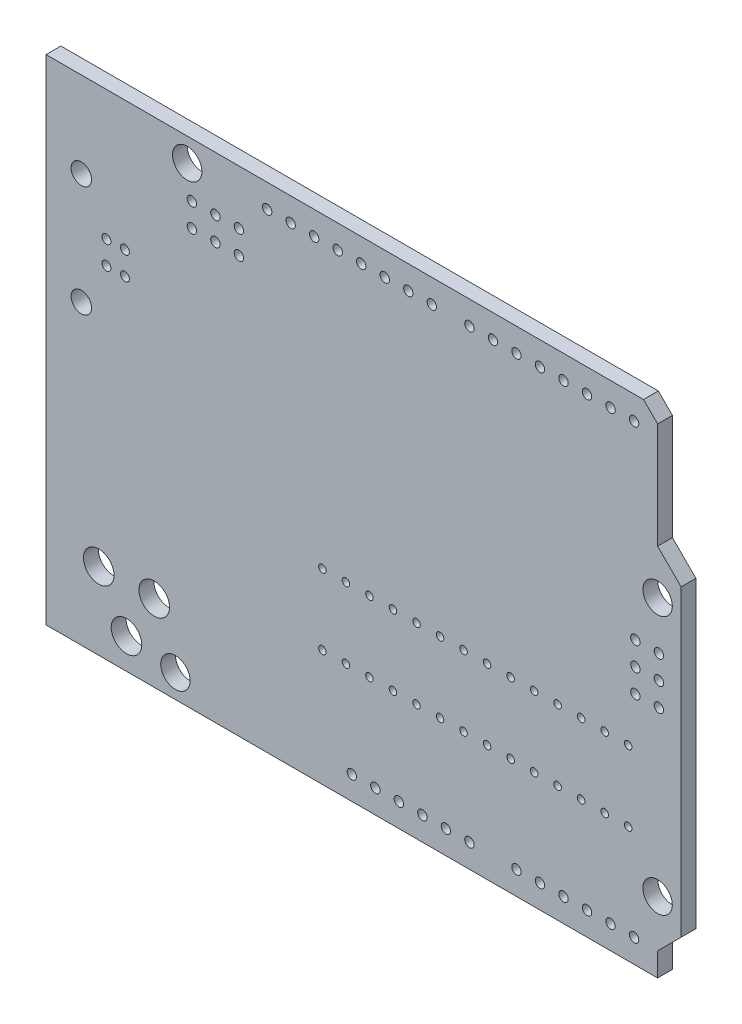
from build123d import *

# Parameters (mm, degrees)
BOSS_EXTRUDE1_DEPTH = 1.6002
SKETCH3_R           = 1.1049
SKETCH3_R_2         = 1.651
SKETCH3_R_3         = 1.5875
SKETCH3_R_4         = 0.4826
CUT_EXTRUDE1_DEPTH  = 2.6002
SKETCH4_R           = 0.508
SKETCH4_R_2         = 0.4064
CUT_EXTRUDE2_DEPTH  = 2.6002


with BuildPart() as part:
    # Sketch2 → Boss-Extrude1 (new body)
    with BuildSketch(Plane.XY):
        Polygon((-34.2899492, 26.67), (30.2259492, 26.67), (31.7499492, 25.146), (31.7499492, 13.716), (34.2899492, 11.176), (34.2899492, -21.59), (31.7499492, -24.13), (31.7499492, -26.67), (-34.2899492, -26.67), align=None)
    extrude(amount=-BOSS_EXTRUDE1_DEPTH)

    # Sketch3 → Cut-Extrude1 (cut, through all)
    with BuildSketch(Plane.XY):
        with Locations((-30.4799492, 17.429988)):
            Circle(SKETCH3_R)
        with Locations((-30.4799492, 5.430012)):
            Circle(SKETCH3_R)
        with Locations((-28.6003492, -18.3642)):
            Circle(SKETCH3_R_2)
        with Locations((-25.6031492, -23.368)):
            Circle(SKETCH3_R_2)
        with Locations((-22.6060508, -18.3642)):
            Circle(SKETCH3_R_2)
        with Locations((31.7499492, -19.05)):
            Circle(SKETCH3_R_3)
        with Locations((31.7499492, 8.89)):
            Circle(SKETCH3_R_3)
        with Locations((-19.0500508, 24.13)):
            Circle(SKETCH3_R_3)
        with Locations((-25.769951, 12.679934)):
            Circle(SKETCH3_R_4)
        with Locations((-27.769947, 12.679934)):
            Circle(SKETCH3_R_4)
        with Locations((-27.769947, 10.180066)):
            Circle(SKETCH3_R_4)
        with Locations((-25.769951, 10.180066)):
            Circle(SKETCH3_R_4)
        with Locations((-20.3200508, -24.13)):
            Circle(SKETCH3_R_3)
    extrude(amount=-CUT_EXTRUDE1_DEPTH, mode=Mode.SUBTRACT)

    # Sketch4 → Cut-Extrude2 (cut, through all)
    with BuildSketch(Plane.XY):
        with Locations((29.2099492, 24.13)):
            Circle(SKETCH4_R)
        with Locations((26.6699492, 24.13)):
            Circle(SKETCH4_R)
        with Locations((24.1299492, 24.13)):
            Circle(SKETCH4_R)
        with Locations((21.5899492, 24.13)):
            Circle(SKETCH4_R)
        with Locations((19.0499492, 24.13)):
            Circle(SKETCH4_R)
        with Locations((16.5099492, 24.13)):
            Circle(SKETCH4_R)
        with Locations((13.9699492, 24.13)):
            Circle(SKETCH4_R)
        with Locations((11.4299492, 24.13)):
            Circle(SKETCH4_R)
        with Locations((7.3659492, 24.13)):
            Circle(SKETCH4_R)
        with Locations((4.8259492, 24.13)):
            Circle(SKETCH4_R)
        with Locations((2.2859492, 24.13)):
            Circle(SKETCH4_R)
        with Locations((-0.2540508, 24.13)):
            Circle(SKETCH4_R)
        with Locations((-2.7940508, 24.13)):
            Circle(SKETCH4_R)
        with Locations((-5.3340508, 24.13)):
            Circle(SKETCH4_R)
        with Locations((-7.8740508, 24.13)):
            Circle(SKETCH4_R)
        with Locations((-10.4140508, 24.13)):
            Circle(SKETCH4_R)
        with Locations((28.5749492, -6.477)):
            Circle(SKETCH4_R_2)
        with Locations((26.0349492, -6.477)):
            Circle(SKETCH4_R_2)
        with Locations((23.4949492, -6.477)):
            Circle(SKETCH4_R_2)
        with Locations((20.9549492, -6.477)):
            Circle(SKETCH4_R_2)
        with Locations((18.4149492, -6.477)):
            Circle(SKETCH4_R_2)
        with Locations((15.8749492, -6.477)):
            Circle(SKETCH4_R_2)
        with Locations((13.3349492, -6.477)):
            Circle(SKETCH4_R_2)
        with Locations((10.7949492, -6.477)):
            Circle(SKETCH4_R_2)
        with Locations((8.2549492, -6.477)):
            Circle(SKETCH4_R_2)
        with Locations((5.7149492, -6.477)):
            Circle(SKETCH4_R_2)
        with Locations((3.1749492, -6.477)):
            Circle(SKETCH4_R_2)
        with Locations((0.6349492, -6.477)):
            Circle(SKETCH4_R_2)
        with Locations((-1.9050508, -6.477)):
            Circle(SKETCH4_R_2)
        with Locations((-4.4450508, -6.477)):
            Circle(SKETCH4_R_2)
        with Locations((28.5749492, -14.097)):
            Circle(SKETCH4_R_2)
        with Locations((26.0349492, -14.097)):
            Circle(SKETCH4_R_2)
        with Locations((23.4949492, -14.097)):
            Circle(SKETCH4_R_2)
        with Locations((20.9549492, -14.097)):
            Circle(SKETCH4_R_2)
        with Locations((18.4149492, -14.097)):
            Circle(SKETCH4_R_2)
        with Locations((15.8749492, -14.097)):
            Circle(SKETCH4_R_2)
        with Locations((13.3349492, -14.097)):
            Circle(SKETCH4_R_2)
        with Locations((10.7949492, -14.097)):
            Circle(SKETCH4_R_2)
        with Locations((8.2549492, -14.097)):
            Circle(SKETCH4_R_2)
        with Locations((5.7149492, -14.097)):
            Circle(SKETCH4_R_2)
        with Locations((3.1749492, -14.097)):
            Circle(SKETCH4_R_2)
        with Locations((0.6349492, -14.097)):
            Circle(SKETCH4_R_2)
        with Locations((-1.9050508, -14.097)):
            Circle(SKETCH4_R_2)
        with Locations((-4.4450508, -14.097)):
            Circle(SKETCH4_R_2)
        with Locations((29.2099492, -24.13)):
            Circle(SKETCH4_R)
        with Locations((11.4299492, -24.13)):
            Circle(SKETCH4_R)
        with Locations((26.6699492, -24.13)):
            Circle(SKETCH4_R)
        with Locations((8.8899492, -24.13)):
            Circle(SKETCH4_R)
        with Locations((24.1299492, -24.13)):
            Circle(SKETCH4_R)
        with Locations((6.3499492, -24.13)):
            Circle(SKETCH4_R)
        with Locations((21.5899492, -24.13)):
            Circle(SKETCH4_R)
        with Locations((3.8099492, -24.13)):
            Circle(SKETCH4_R)
        with Locations((19.0499492, -24.13)):
            Circle(SKETCH4_R)
        with Locations((1.2699492, -24.13)):
            Circle(SKETCH4_R)
        with Locations((16.5099492, -24.13)):
            Circle(SKETCH4_R)
        with Locations((-1.2700508, -24.13)):
            Circle(SKETCH4_R)
        with Locations((-13.4620508, 20.828)):
            Circle(SKETCH4_R)
        with Locations((-13.4620508, 18.288)):
            Circle(SKETCH4_R)
        with Locations((-16.0020508, 18.288)):
            Circle(SKETCH4_R)
        with Locations((-16.0020508, 20.828)):
            Circle(SKETCH4_R)
        with Locations((-18.5420508, 18.288)):
            Circle(SKETCH4_R)
        with Locations((-18.5420508, 20.828)):
            Circle(SKETCH4_R)
        with Locations((31.8901572, -1.320038)):
            Circle(SKETCH4_R)
        with Locations((29.3501572, -1.320038)):
            Circle(SKETCH4_R)
        with Locations((29.3501572, 1.219962)):
            Circle(SKETCH4_R)
        with Locations((31.8901572, 1.219962)):
            Circle(SKETCH4_R)
        with Locations((29.3501572, 3.759962)):
            Circle(SKETCH4_R)
        with Locations((31.8901572, 3.759962)):
            Circle(SKETCH4_R)
    extrude(amount=-CUT_EXTRUDE2_DEPTH, mode=Mode.SUBTRACT)


solid = part.part
